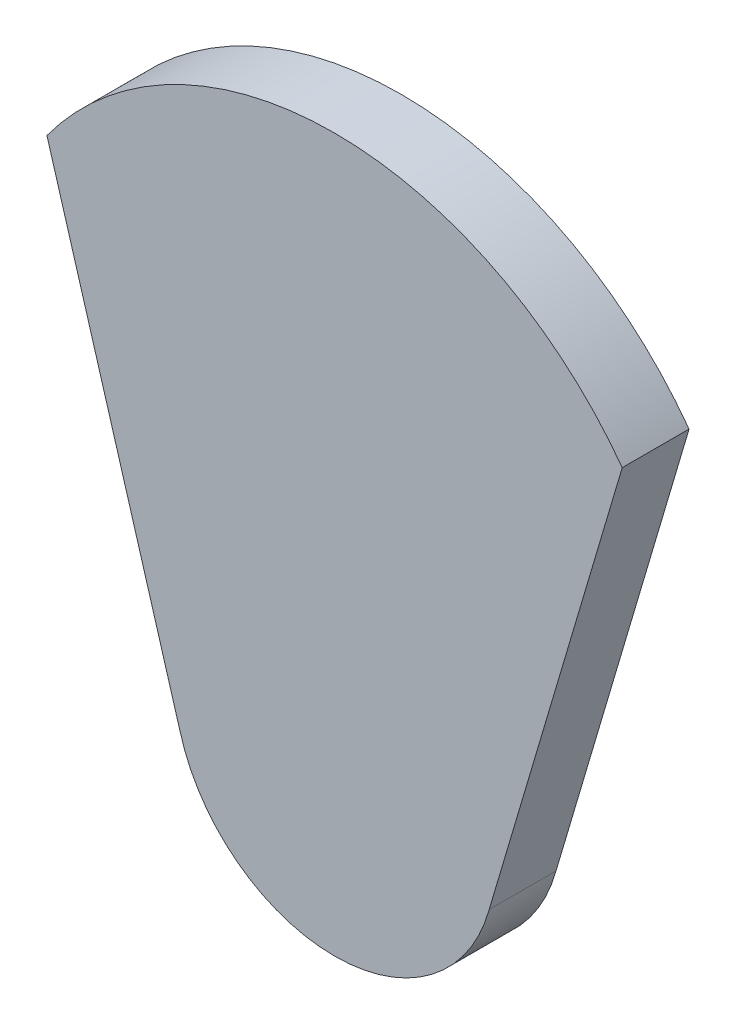
from build123d import *

# Parameters (mm, degrees)
BOSS_EXTRUDE1_DEPTH = 381


with BuildPart() as part:
    # Sketch1 → Boss-Extrude1 (new body)
    with BuildSketch(Plane.XY):
        with BuildLine():
            ThreePointArc((1639.965497995, 1199.807136745), (0, 2032), (-1639.965497995, 1199.807136745))
            Line((-1639.965497995, 1199.807136745), (-881.273799142, -1361.493113772))
            ThreePointArc((-881.273799142, -1361.493113772), (0, -2032), (881.273799142, -1361.493113772))
            Line((881.273799142, -1361.493113772), (1639.965497995, 1199.807136745))
        make_face()
    extrude(amount=BOSS_EXTRUDE1_DEPTH)


solid = part.part
